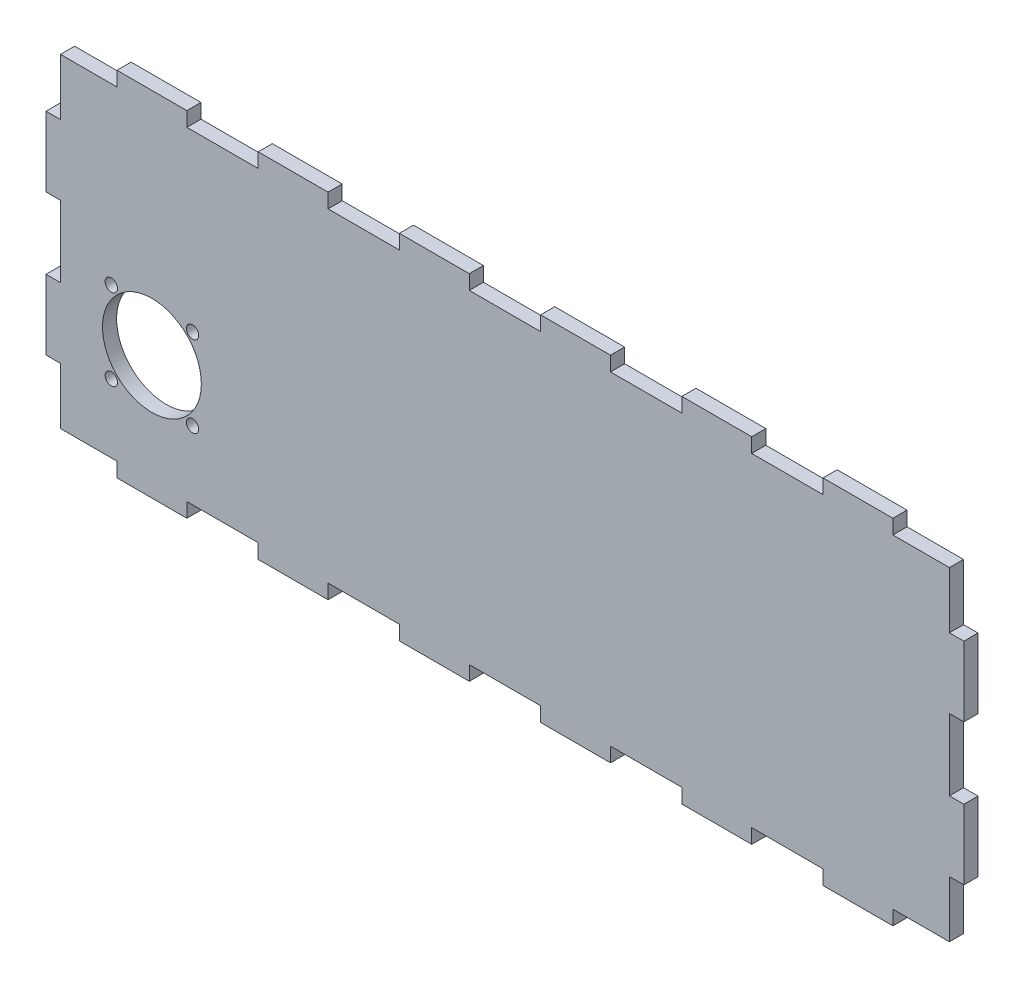
from build123d import *

# Parameters (mm, degrees)
SKETCH2_W               = 260
SKETCH2_H               = 100
BOSS_EXTRUDE1_DEPTH     = 4
SKETCH3_W               = 4.1
SKETCH3_H               = 20.2
CUT_EXTRUDE1_DEPTH      = 4
LPATTERN1_COUNT         = 3
LPATTERN1_PITCH         = 40
MIRROR1_COPY_1_SKETCH_W = 4.1
MIRROR1_COPY_1_SKETCH_H = 20.2
MIRROR1_COPY_1_DEPTH    = 4
MIRROR1_COPY_2_SKETCH_W = 4.1
MIRROR1_COPY_2_SKETCH_H = 20.2
MIRROR1_COPY_2_DEPTH    = 4
SKETCH4_W               = 20.2
SKETCH4_H               = 4.1
CUT_EXTRUDE2_DEPTH      = 4
LPATTERN2_COUNT         = 7
LPATTERN2_PITCH         = 40
MIRROR2_COPY_1_SKETCH_W = 20.2
MIRROR2_COPY_1_SKETCH_H = 4.1
MIRROR2_COPY_1_DEPTH    = 4
MIRROR2_COPY_2_SKETCH_W = 20.2
MIRROR2_COPY_2_SKETCH_H = 4.1
MIRROR2_COPY_2_DEPTH    = 4
MIRROR2_COPY_3_SKETCH_W = 20.2
MIRROR2_COPY_3_SKETCH_H = 4.1
MIRROR2_COPY_3_DEPTH    = 4
MIRROR2_COPY_4_SKETCH_W = 20.2
MIRROR2_COPY_4_SKETCH_H = 4.1
MIRROR2_COPY_4_DEPTH    = 4
MIRROR2_COPY_5_SKETCH_W = 20.2
MIRROR2_COPY_5_SKETCH_H = 4.1
MIRROR2_COPY_5_DEPTH    = 4
MIRROR2_COPY_6_SKETCH_W = 20.2
MIRROR2_COPY_6_SKETCH_H = 4.1
MIRROR2_COPY_6_DEPTH    = 4
SKETCH5_R               = 14
SKETCH5_R_2             = 1.75
CUT_EXTRUDE3_DEPTH      = 5


with BuildPart() as part:
    # Sketch2 → Boss-Extrude1 (new body)
    with BuildSketch(Plane.XY):
        Rectangle(SKETCH2_W, SKETCH2_H)
    extrude(amount=BOSS_EXTRUDE1_DEPTH)

    # Sketch3 → Cut-Extrude1 (cut)
    with BuildSketch(Plane.XY.offset(4)):
        with Locations((-127.95, -40)):
            Rectangle(SKETCH3_W, SKETCH3_H)
    cut_extrude1 = extrude(amount=-CUT_EXTRUDE1_DEPTH, mode=Mode.SUBTRACT)

    # LPattern1: Cut-Extrude1 ×3
    with Locations(*[(0, i * LPATTERN1_PITCH, 0) for i in range(1, LPATTERN1_COUNT)]):
        add(cut_extrude1, mode=Mode.SUBTRACT)

    # Mirror1: Cut-Extrude1 across plane
    add(cut_extrude1.mirror(Plane(origin=(0, 0, 0), x_dir=(0, 0, 1), z_dir=(1, 0, 0))), mode=Mode.SUBTRACT)

    # Mirror1 copy 1 sketch → Mirror1 copy 1 (cut)
    with BuildSketch(Plane(origin=(0, 40, 4), x_dir=(-1, 0, 0), z_dir=(0, 0, 1))):
        with Locations((-127.95, 40)):
            Rectangle(MIRROR1_COPY_1_SKETCH_W, MIRROR1_COPY_1_SKETCH_H)
    extrude(amount=-MIRROR1_COPY_1_DEPTH, mode=Mode.SUBTRACT)

    # Mirror1 copy 2 sketch → Mirror1 copy 2 (cut)
    with BuildSketch(Plane(origin=(0, 80, 4), x_dir=(-1, 0, 0), z_dir=(0, 0, 1))):
        with Locations((-127.95, 40)):
            Rectangle(MIRROR1_COPY_2_SKETCH_W, MIRROR1_COPY_2_SKETCH_H)
    extrude(amount=-MIRROR1_COPY_2_DEPTH, mode=Mode.SUBTRACT)

    # Sketch4 → Cut-Extrude2 (cut)
    with BuildSketch(Plane.XY.offset(4)):
        with Locations((-120, -47.95)):
            Rectangle(SKETCH4_W, SKETCH4_H)
    cut_extrude2 = extrude(amount=-CUT_EXTRUDE2_DEPTH, mode=Mode.SUBTRACT)

    # LPattern2: Cut-Extrude2 ×7
    with Locations(*[(i * LPATTERN2_PITCH, 0, 0) for i in range(1, LPATTERN2_COUNT)]):
        add(cut_extrude2, mode=Mode.SUBTRACT)

    # Mirror2: Cut-Extrude2 across plane
    add(cut_extrude2.mirror(Plane.ZX), mode=Mode.SUBTRACT)

    # Mirror2 copy 1 sketch → Mirror2 copy 1 (cut)
    with BuildSketch(Plane(origin=(40, 0, 4), x_dir=(1, 0, 0), z_dir=(0, 0, 1))):
        with Locations((-120, 47.95)):
            Rectangle(MIRROR2_COPY_1_SKETCH_W, MIRROR2_COPY_1_SKETCH_H)
    extrude(amount=-MIRROR2_COPY_1_DEPTH, mode=Mode.SUBTRACT)

    # Mirror2 copy 2 sketch → Mirror2 copy 2 (cut)
    with BuildSketch(Plane(origin=(80, 0, 4), x_dir=(1, 0, 0), z_dir=(0, 0, 1))):
        with Locations((-120, 47.95)):
            Rectangle(MIRROR2_COPY_2_SKETCH_W, MIRROR2_COPY_2_SKETCH_H)
    extrude(amount=-MIRROR2_COPY_2_DEPTH, mode=Mode.SUBTRACT)

    # Mirror2 copy 3 sketch → Mirror2 copy 3 (cut)
    with BuildSketch(Plane(origin=(120, 0, 4), x_dir=(1, 0, 0), z_dir=(0, 0, 1))):
        with Locations((-120, 47.95)):
            Rectangle(MIRROR2_COPY_3_SKETCH_W, MIRROR2_COPY_3_SKETCH_H)
    extrude(amount=-MIRROR2_COPY_3_DEPTH, mode=Mode.SUBTRACT)

    # Mirror2 copy 4 sketch → Mirror2 copy 4 (cut)
    with BuildSketch(Plane(origin=(160, 0, 4), x_dir=(1, 0, 0), z_dir=(0, 0, 1))):
        with Locations((-120, 47.95)):
            Rectangle(MIRROR2_COPY_4_SKETCH_W, MIRROR2_COPY_4_SKETCH_H)
    extrude(amount=-MIRROR2_COPY_4_DEPTH, mode=Mode.SUBTRACT)

    # Mirror2 copy 5 sketch → Mirror2 copy 5 (cut)
    with BuildSketch(Plane(origin=(200, 0, 4), x_dir=(1, 0, 0), z_dir=(0, 0, 1))):
        with Locations((-120, 47.95)):
            Rectangle(MIRROR2_COPY_5_SKETCH_W, MIRROR2_COPY_5_SKETCH_H)
    extrude(amount=-MIRROR2_COPY_5_DEPTH, mode=Mode.SUBTRACT)

    # Mirror2 copy 6 sketch → Mirror2 copy 6 (cut)
    with BuildSketch(Plane(origin=(240, 0, 4), x_dir=(1, 0, 0), z_dir=(0, 0, 1))):
        with Locations((-120, 47.95)):
            Rectangle(MIRROR2_COPY_6_SKETCH_W, MIRROR2_COPY_6_SKETCH_H)
    extrude(amount=-MIRROR2_COPY_6_DEPTH, mode=Mode.SUBTRACT)

    # Sketch5 → Cut-Extrude3 (cut, through all)
    with BuildSketch(Plane.XY.offset(4)):
        with Locations((-100, -15)):
            Circle(SKETCH5_R)
        with Locations((-111.5, -3.5)):
            Circle(SKETCH5_R_2)
        with Locations((-88.5, -3.5)):
            Circle(SKETCH5_R_2)
        with Locations((-111.5, -26.5)):
            Circle(SKETCH5_R_2)
        with Locations((-88.5, -26.5)):
            Circle(SKETCH5_R_2)
    extrude(amount=-CUT_EXTRUDE3_DEPTH, mode=Mode.SUBTRACT)


solid = part.part
